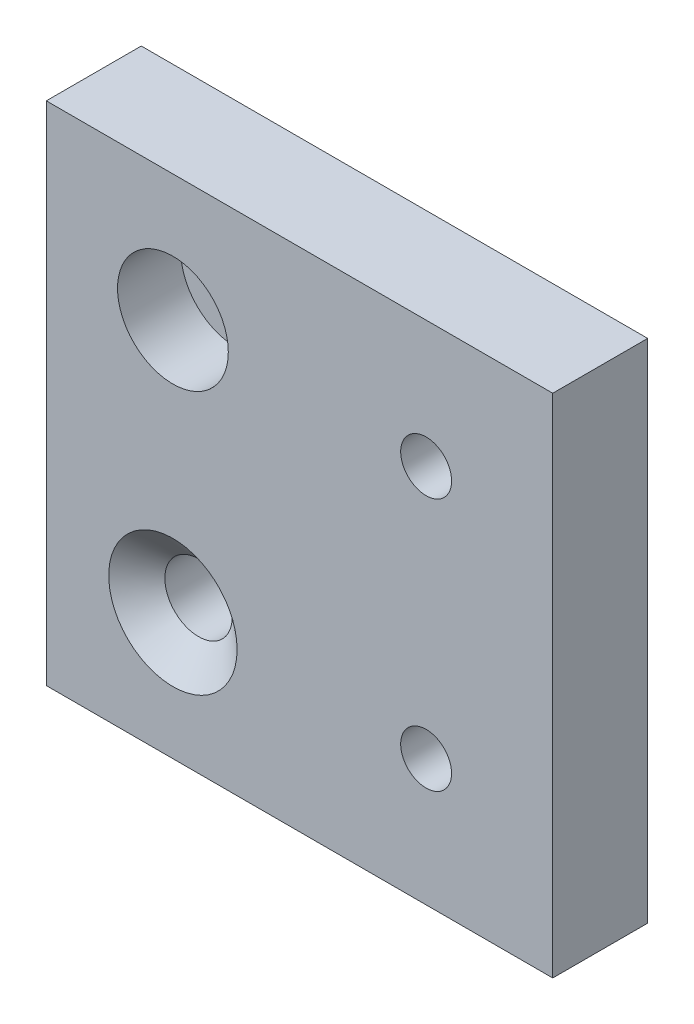
from build123d import *

# Parameters (mm, degrees)
SKETCH1_W                                           = 50.8
SKETCH1_H                                           = 50.8
BOSS_EXTRUDE1_DEPTH                                 = 9.525
CBORE_FOR_1_4_SOCKET_HEAD_CAP_SCREW1_D              = 6.7564
CBORE_FOR_1_4_SOCKET_HEAD_CAP_SCREW1_CBORE_D        = 11.1125
CBORE_FOR_1_4_SOCKET_HEAD_CAP_SCREW1_CBORE_DEPTH    = 6.35
F_1_4_20_TAPPED_HOLE1_D                             = 5.1054
CSK_FOR_1_4_FLAT_HEAD_MACHINE_SCREW_100_D           = 6.7564
CSK_FOR_1_4_FLAT_HEAD_MACHINE_SCREW_100_CSINK_D     = 12.8778
CSK_FOR_1_4_FLAT_HEAD_MACHINE_SCREW_100_CSINK_ANGLE = 100


with BuildPart() as part:
    # Sketch1 → Boss-Extrude1 (new body)
    with BuildSketch(Plane.XY):
        with Locations((25.4, 25.4)):
            Rectangle(SKETCH1_W, SKETCH1_H)
    extrude(amount=BOSS_EXTRUDE1_DEPTH)

    # CBORE for 1/4 Socket Head Cap Screw1 (through all)
    with Locations(Plane.XY.offset(9.525)):
        with Locations((12.7, 38.1)):
            CounterBoreHole(CBORE_FOR_1_4_SOCKET_HEAD_CAP_SCREW1_D / 2, CBORE_FOR_1_4_SOCKET_HEAD_CAP_SCREW1_CBORE_D / 2, CBORE_FOR_1_4_SOCKET_HEAD_CAP_SCREW1_CBORE_DEPTH)

    # 1/4-20 Tapped Hole1 (through all)
    with Locations(Plane.XY.offset(9.525)):
        with Locations((38.1, 38.1), (38.1, 12.7)):
            Hole(F_1_4_20_TAPPED_HOLE1_D / 2)

    # CSK for 1/4 Flat Head Machine Screw (100)1 (through all)
    with Locations(Plane.XY.offset(9.525)):
        with Locations((12.7, 12.7)):
            CounterSinkHole(CSK_FOR_1_4_FLAT_HEAD_MACHINE_SCREW_100_D / 2, CSK_FOR_1_4_FLAT_HEAD_MACHINE_SCREW_100_CSINK_D / 2, counter_sink_angle=CSK_FOR_1_4_FLAT_HEAD_MACHINE_SCREW_100_CSINK_ANGLE)


solid = part.part
